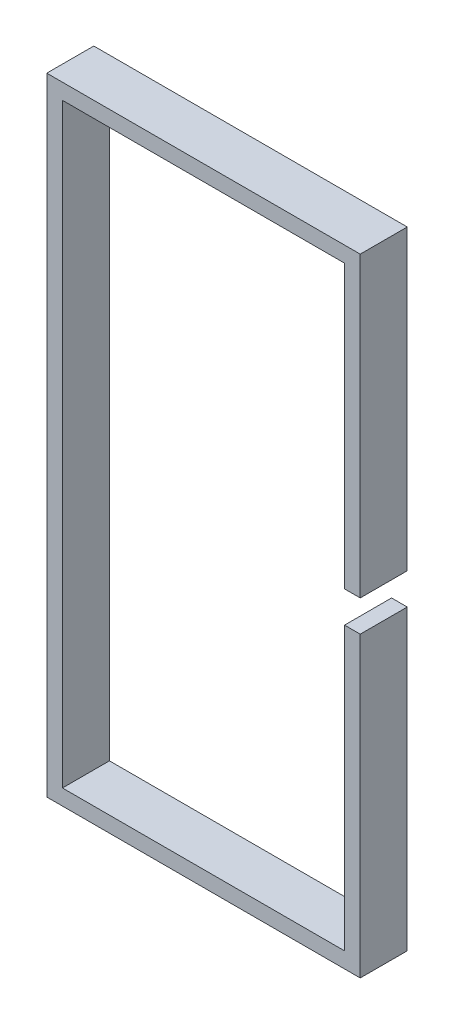
from build123d import *

# Parameters (mm, degrees)
EXTRUDE_THIN1_DEPTH = 30


with BuildPart() as part:
    # Sketch1 → Extrude-Thin1 (new body)
    with BuildSketch(Plane.XY):
        Polygon((0, -190), (0, 0), (-200, 0), (-200, -400), (0, -400), (0, -210), (-10, -210), (-10, -390), (-190, -390), (-190, -10), (-10, -10), (-10, -190), align=None)
    extrude(amount=EXTRUDE_THIN1_DEPTH)


solid = part.part
